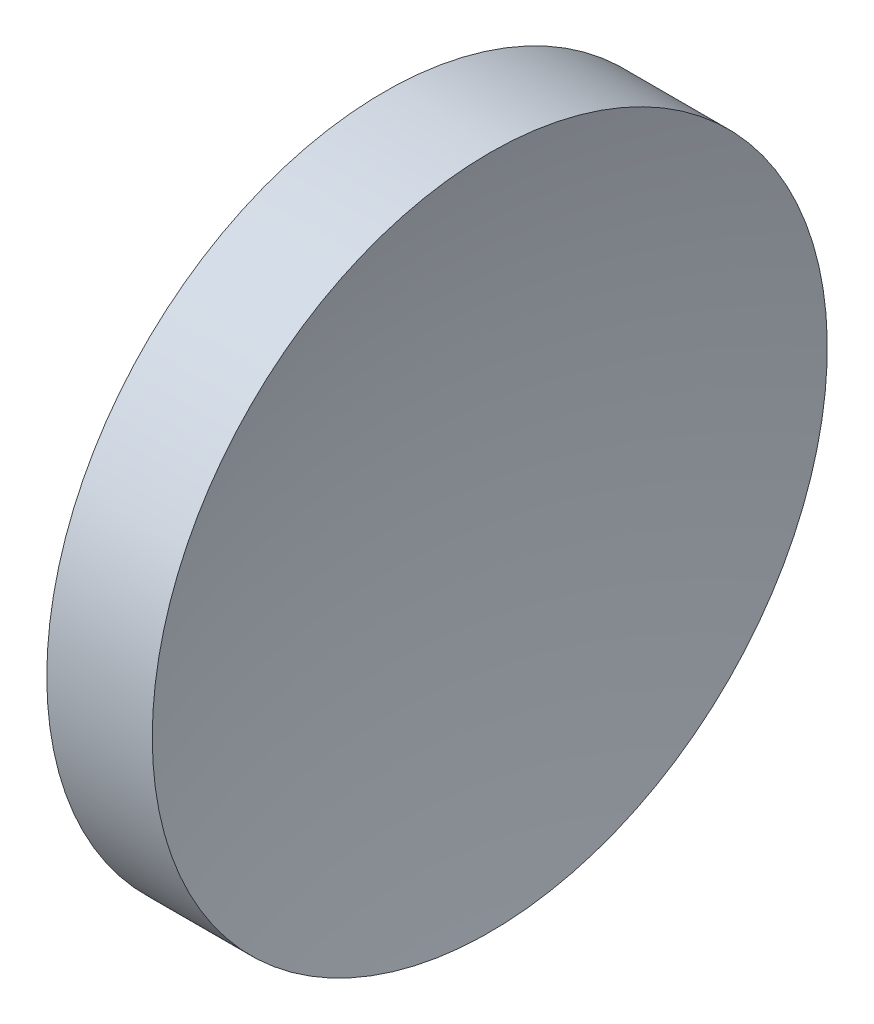
from build123d import *


with BuildPart() as part:
    # 草图1 → 旋转1 (revolve)
    with BuildSketch(Plane.XY):
        with BuildLine():
            Line((44.319152693, 26.089041149), (44.319152693, 34.089041149))
            Line((44.319152693, 34.089041149), (46.819152658, 34.089041149))
            ThreePointArc((46.819152658, 34.089041149), (46.070121664, 30.120170023), (45.819152658, 26.089041149))
            Line((45.819152658, 26.089041149), (44.319152693, 26.089041149))
        make_face()
    revolve(axis=Axis((42.449861114, 26.089041149, 0), (1, 0, 0)))


solid = part.part
